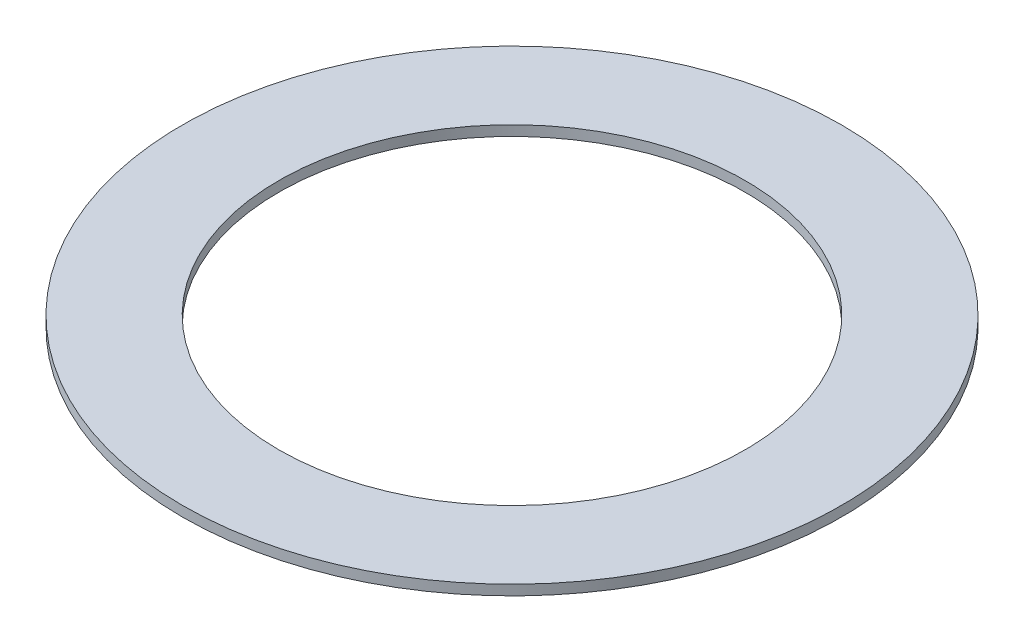
from build123d import *

# Parameters (mm, degrees)
SKETCH1_R      = 32.5
SKETCH1_R_2    = 23
EXTRUDE1_DEPTH = 1


with BuildPart() as part:
    # Sketch1 → Extrude1 (new body)
    with BuildSketch(Plane(origin=(0, 0, 0), x_dir=(1, 0, 0), z_dir=(0, 1, 0))):
        Circle(SKETCH1_R)
        Circle(SKETCH1_R_2, mode=Mode.SUBTRACT)
    extrude(amount=EXTRUDE1_DEPTH)


solid = part.part
